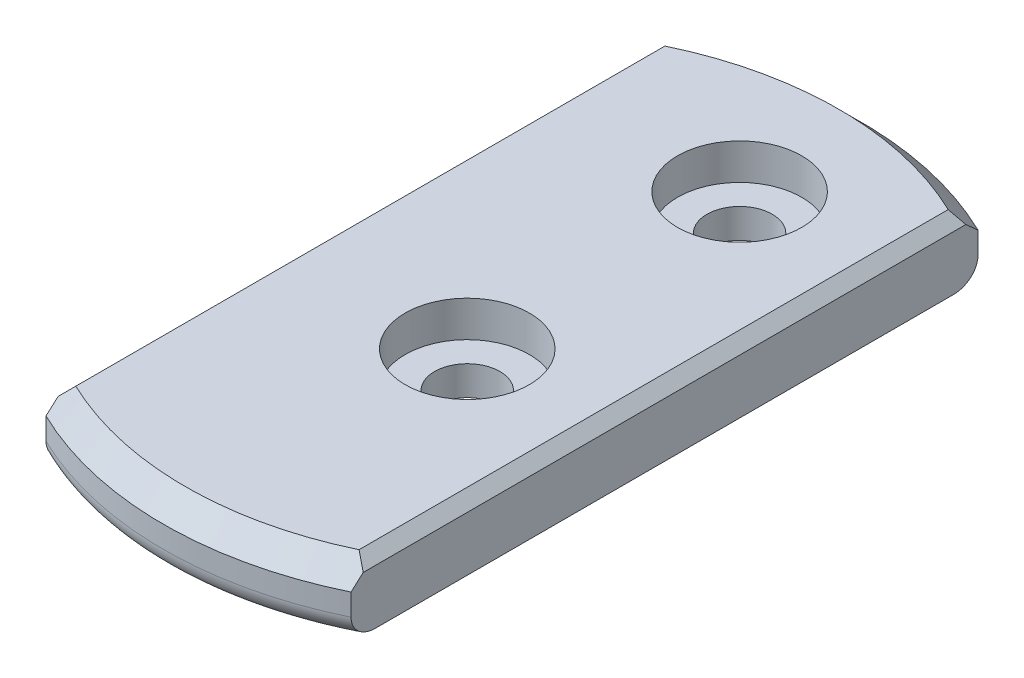
from build123d import *

# Parameters (mm, degrees)
SKETCH2_R           = 16
BOSS_EXTRUDE1_DEPTH = 3
SKETCH1_W           = 9
SKETCH1_H           = 32
CUT_EXTRUDE1_DEPTH  = 4
SKETCH3_R           = 1.5
CUT_EXTRUDE2_DEPTH  = 4
SKETCH4_R           = 2.85
CUT_EXTRUDE3_DEPTH  = 1.65
CHAMFER1_SIZE       = 0.5
FILLET1_R           = 1
CHAMFER2_SIZE       = 1


with BuildPart() as part:
    # Sketch2 → Boss-Extrude1 (new body)
    with BuildSketch(Plane(origin=(0, 0, 0), x_dir=(1, 0, 0), z_dir=(0, 1, 0))):
        Circle(SKETCH2_R)
    extrude(amount=BOSS_EXTRUDE1_DEPTH)

    # Sketch1 → Cut-Extrude1 (cut, through all)
    with BuildSketch(Plane(origin=(0, 0, 0), x_dir=(1, 0, 0), z_dir=(0, 1, 0))):
        with Locations((-11.5, 0)):
            Rectangle(SKETCH1_W, SKETCH1_H)
        with Locations((11.5, 0)):
            Rectangle(SKETCH1_W, SKETCH1_H)
    extrude(amount=CUT_EXTRUDE1_DEPTH, mode=Mode.SUBTRACT)

    # Sketch3 → Cut-Extrude2 (cut, through all)
    with BuildSketch(Plane(origin=(0, 3, 0), x_dir=(1, 0, 0), z_dir=(0, 1, 0))):
        with Locations((1, 9.4472)):
            Circle(SKETCH3_R)
        with Locations((1, -3.0528)):
            Circle(SKETCH3_R)
    extrude(amount=-CUT_EXTRUDE2_DEPTH, mode=Mode.SUBTRACT)

    # Sketch4 → Cut-Extrude3 (cut)
    with BuildSketch(Plane(origin=(0, 3, 0), x_dir=(1, 0, 0), z_dir=(0, 1, 0))):
        with Locations((1, 9.4472)):
            Circle(SKETCH4_R)
        with Locations((1, -3.0528)):
            Circle(SKETCH4_R)
    extrude(amount=-CUT_EXTRUDE3_DEPTH, mode=Mode.SUBTRACT)

    # Chamfer1
    chamfer1_edges = [part.edges().sort_by_distance(p)[0] for p in [
        (-7, 3, 0),
        (7, 3, 0),
    ]]
    chamfer(chamfer1_edges, length=CHAMFER1_SIZE)

    # Fillet1
    fillet1_edges = [part.edges().sort_by_distance(p)[0] for p in [
        (0, 0, -16),
        (0, 0, 16),
    ]]
    fillet(fillet1_edges, radius=FILLET1_R)

    # Chamfer2
    chamfer2_edges = [part.edges().sort_by_distance(p)[0] for p in [
        (0, 3, -16),
        (0, 3, 16),
    ]]
    chamfer(chamfer2_edges, length=CHAMFER2_SIZE)


solid = part.part
